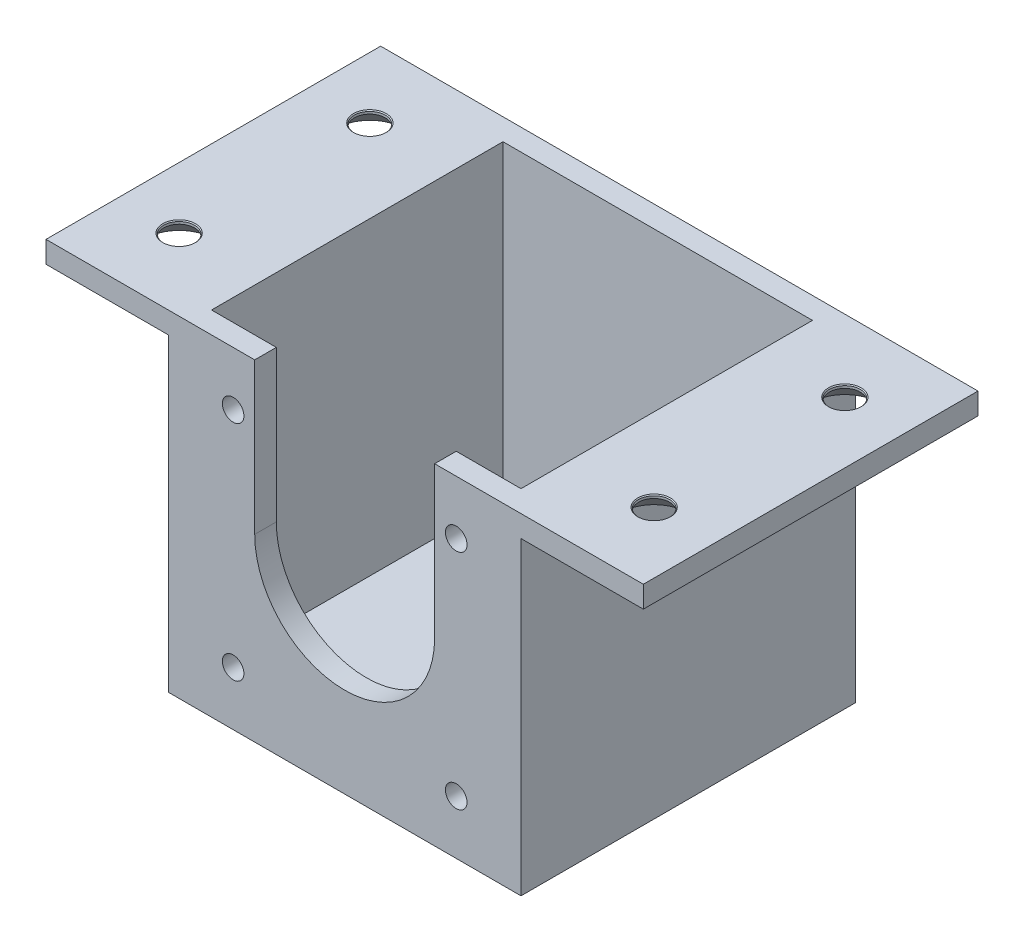
from build123d import *

# Parameters (mm, degrees)
EXTRU_MINCE1_DEPTH                          = 46.5
ESQUISSE2_W                                 = 43
ESQUISSE2_H                                 = 3
BOSS_EXTRU_1_DEPTH                          = 43
ENL_V_MAT_EXTRU_1_REACH                     = 48.5
ESQUISSE3_R                                 = 1.5
FRAISAGE_POUR_VIS_T_TE_FRAIS_E_M41_AT_COUNT = 2
FRAISAGE_POUR_VIS_T_TE_FRAIS_E_M41_AT_PITCH = 71.121375127
FRAISAGE_POUR_VIS_T_TE_FRAIS_E_M41_2_COUNT  = 2
FRAISAGE_POUR_VIS_T_TE_FRAIS_E_M41_2_PITCH  = 66
FRAISAGE_POUR_VIS_T_TE_FRAIS_E_M41_3_COUNT  = 2
FRAISAGE_POUR_VIS_T_TE_FRAIS_E_M41_3_PITCH  = 26.5
ESQUISSE6_W                                 = 25
ESQUISSE6_H                                 = 15
ENL_V_MAT_EXTRU_2_DEPTH                     = 5


with BuildPart() as part:
    # Esquisse1 → Extru.-Mince1 (new body)
    with BuildSketch(Plane.XY):
        Polygon((20, 43), (0, 43), (0, 0), (-43, 0), (-43, 43), (-63, 43), (-63, 40), (-46, 40), (-46, -3), (3, -3), (3, 40), (20, 40), align=None)
    extrude(amount=EXTRU_MINCE1_DEPTH)

    # Esquisse2 → Boss.-Extru.1 (add)
    with BuildSketch(Plane(origin=(0, 0, 0), x_dir=(1, 0, 0), z_dir=(0, 1, 0))):
        with Locations((-21.5, -1.5)):
            Rectangle(ESQUISSE2_W, ESQUISSE2_H)
        with Locations((-21.5, -45)):
            Rectangle(ESQUISSE2_W, ESQUISSE2_H)
    extrude(amount=BOSS_EXTRU_1_DEPTH)

    # Esquisse3 → Enlèv. mat.-Extru.1 (cut, up to next)
    with BuildSketch(Plane.XY.offset(46.5), mode=Mode.PRIVATE) as enl_v_mat_extru_1_sk1:
        with Locations((-37, 4.5)):
            Circle(ESQUISSE3_R)
    enl_v_mat_extru_1_tool1 = extrude(enl_v_mat_extru_1_sk1.sketch, amount=-ENL_V_MAT_EXTRU_1_REACH, mode=Mode.PRIVATE) & part.part
    add(enl_v_mat_extru_1_tool1.solids().sort_by_distance((-37, 4.5, 46.5))[0], mode=Mode.SUBTRACT)
    # Esquisse3 → Enlèv. mat.-Extru.1 (cut, up to next)
    with BuildSketch(Plane.XY.offset(46.5), mode=Mode.PRIVATE) as enl_v_mat_extru_1_sk2:
        with Locations((-37, 35.5)):
            Circle(ESQUISSE3_R)
    enl_v_mat_extru_1_tool2 = extrude(enl_v_mat_extru_1_sk2.sketch, amount=-ENL_V_MAT_EXTRU_1_REACH, mode=Mode.PRIVATE) & part.part
    add(enl_v_mat_extru_1_tool2.solids().sort_by_distance((-37, 35.5, 46.5))[0], mode=Mode.SUBTRACT)
    # Esquisse3 → Enlèv. mat.-Extru.1 (cut, up to next)
    with BuildSketch(Plane.XY.offset(46.5), mode=Mode.PRIVATE) as enl_v_mat_extru_1_sk3:
        with Locations((-6, 35.5)):
            Circle(ESQUISSE3_R)
    enl_v_mat_extru_1_tool3 = extrude(enl_v_mat_extru_1_sk3.sketch, amount=-ENL_V_MAT_EXTRU_1_REACH, mode=Mode.PRIVATE) & part.part
    add(enl_v_mat_extru_1_tool3.solids().sort_by_distance((-6, 35.5, 46.5))[0], mode=Mode.SUBTRACT)
    # Esquisse3 → Enlèv. mat.-Extru.1 (cut, up to next)
    with BuildSketch(Plane.XY.offset(46.5), mode=Mode.PRIVATE) as enl_v_mat_extru_1_sk4:
        with Locations((-6, 4.5)):
            Circle(ESQUISSE3_R)
    enl_v_mat_extru_1_tool4 = extrude(enl_v_mat_extru_1_sk4.sketch, amount=-ENL_V_MAT_EXTRU_1_REACH, mode=Mode.PRIVATE) & part.part
    add(enl_v_mat_extru_1_tool4.solids().sort_by_distance((-6, 4.5, 46.5))[0], mode=Mode.SUBTRACT)
    # Esquisse3 → Enlèv. mat.-Extru.1 (cut, up to next)
    with BuildSketch(Plane.XY.offset(46.5), mode=Mode.PRIVATE) as enl_v_mat_extru_1_sk5:
        with BuildLine():
            Line((-34, 43), (-9, 43))
            Line((-9, 43), (-9, 22))
            ThreePointArc((-9, 22), (-21.5, 9.5), (-34, 22))
            Line((-34, 22), (-34, 43))
        make_face()
    enl_v_mat_extru_1_tool5 = extrude(enl_v_mat_extru_1_sk5.sketch, amount=-ENL_V_MAT_EXTRU_1_REACH, mode=Mode.PRIVATE) & part.part
    add(enl_v_mat_extru_1_tool5.solids().sort_by_distance((-21.5, 27.464973, 46.5))[0], mode=Mode.SUBTRACT)

    # Esquisse5 → Fraisage pour vis à tête fraisée M41 (revolve, cut)
    with BuildSketch(Plane(origin=(-54.5, 40, 36.5), x_dir=(0, 0, -1), z_dir=(1, 0, 0))):
        Polygon((0, 0), (0, 3), (2.275, 3), (2.15, 2.875), (2.15, 2.55), (4.7, 0), align=None)
    fraisage_pour_vis_t_te_frais_e_m41 = revolve(axis=Axis((-54.5, 33.65, 36.5), (0, 1, 0)), mode=Mode.SUBTRACT)

    # Fraisage pour vis à tête fraisée M41 at: Fraisage pour vis à tête fraisée M41 ×2
    with Locations(*[Vector(0.927991056, 0, -0.372602469) * (i * FRAISAGE_POUR_VIS_T_TE_FRAIS_E_M41_AT_PITCH) for i in range(1, FRAISAGE_POUR_VIS_T_TE_FRAIS_E_M41_AT_COUNT)]):
        add(fraisage_pour_vis_t_te_frais_e_m41, mode=Mode.SUBTRACT)

    # Fraisage pour vis _ t_te frais_e M41 2: Fraisage pour vis à tête fraisée M41 ×2
    with Locations(*[(i * FRAISAGE_POUR_VIS_T_TE_FRAIS_E_M41_2_PITCH, 0, 0) for i in range(1, FRAISAGE_POUR_VIS_T_TE_FRAIS_E_M41_2_COUNT)]):
        add(fraisage_pour_vis_t_te_frais_e_m41, mode=Mode.SUBTRACT)

    # Fraisage pour vis _ t_te frais_e M41 3: Fraisage pour vis à tête fraisée M41 ×2
    with Locations(*[(0, 0, -i * FRAISAGE_POUR_VIS_T_TE_FRAIS_E_M41_3_PITCH) for i in range(1, FRAISAGE_POUR_VIS_T_TE_FRAIS_E_M41_3_COUNT)]):
        add(fraisage_pour_vis_t_te_frais_e_m41, mode=Mode.SUBTRACT)

    # Esquisse6 → Enlèv. mat.-Extru.2 (cut)
    with BuildSketch(Plane.XZ.offset(3)):
        with Locations((-21.5, 7.5)):
            Rectangle(ESQUISSE6_W, ESQUISSE6_H)
    extrude(amount=-ENL_V_MAT_EXTRU_2_DEPTH, mode=Mode.SUBTRACT)


solid = part.part
